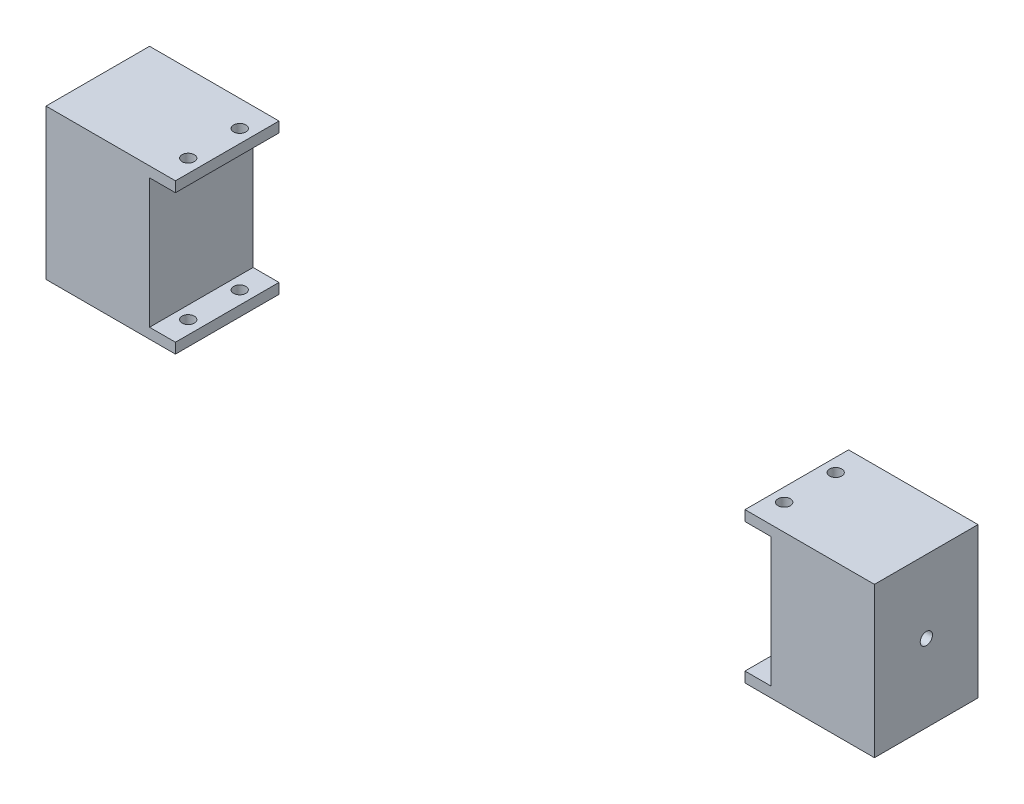
from build123d import *

# Parameters (mm, degrees)
SKETCH1_W                   = 25.4
SKETCH1_H                   = 25.4
MIAN_DEPTH                  = 31.75
SKETCH1_3_W                 = 6.35
SKETCH1_3_H                 = 25.4
SKETCH1_3_W_2               = 25.4
BOTTOM_LIP_DEPTH            = 2.54
TOP_START                   = 31.75
SKETCH1_4_W                 = 25.4
SKETCH1_4_H                 = 25.4
SKETCH1_4_W_2               = 6.35
TOP_LIP_DEPTH               = 2.54
HOLE_WIZARD_1474_AT_2_COUNT = 2
HOLE_WIZARD_1474_AT_2_PITCH = 12.636677574


with BuildPart() as part:
    # Sketch1 → mian (new body)
    with BuildSketch(Plane(origin=(0, 0, 0), x_dir=(1, 0, 0), z_dir=(0, 1, 0))):
        with Locations((-88.9, -12.7)):
            Rectangle(SKETCH1_W, SKETCH1_H)
    extrude(amount=MIAN_DEPTH)

    # Sketch1_3 → bottom lip (add)
    with BuildSketch(Plane(origin=(0, 0, 0), x_dir=(1, 0, 0), z_dir=(0, 1, 0))):
        with Locations((-73.025, -12.7)):
            Rectangle(SKETCH1_3_W, SKETCH1_3_H)
        with Locations((-88.9, -12.7)):
            Rectangle(SKETCH1_3_W_2, SKETCH1_3_H)
    extrude(amount=-BOTTOM_LIP_DEPTH)

    # Sketch1_4 → top lip (add)
    with BuildSketch(Plane(origin=(0, 0, 0), x_dir=(1, 0, 0), z_dir=(0, 1, 0)).offset(TOP_START)):
        with Locations((-88.9, -12.7)):
            Rectangle(SKETCH1_4_W, SKETCH1_4_H)
        with Locations((-73.025, -12.7)):
            Rectangle(SKETCH1_4_W_2, SKETCH1_4_H)
    extrude(amount=TOP_LIP_DEPTH)

    # Sketch10 → Hole Wizard 1474 (revolve, cut)
    with BuildSketch(Plane(origin=(-73.086678341, -2.54, 6.394154505), x_dir=(0, 0, -1), z_dir=(1, 0, 0))):
        Polygon((0, 0), (0, 8.521290929), (1.5, 7.62), (1.5, 0), align=None)
    hole_wizard_1474 = revolve(axis=Axis((-73.086678341, -8.89, 6.394154505), (0, 1, 0)), mode=Mode.SUBTRACT)

    # Hole Wizard 1474 at 2: Hole Wizard 1474 ×2
    with Locations(*[(0, 0, i * HOLE_WIZARD_1474_AT_2_PITCH) for i in range(1, HOLE_WIZARD_1474_AT_2_COUNT)]):
        add(hole_wizard_1474, mode=Mode.SUBTRACT)

    # Mirror4: Hole Wizard 1474 across plane
    add(hole_wizard_1474.mirror(Plane.ZX.offset(15.875)), mode=Mode.SUBTRACT)

    # Mirror4 copy 1 sketch → Mirror4 copy 1 (revolve, cut)
    with BuildSketch(Plane(origin=(-73.086678341, 34.29, 19.030832079), x_dir=(0, 0, -1), z_dir=(1, 0, 0))):
        Polygon((0, 0), (0, -8.521290929), (1.5, -7.62), (1.5, 0), align=None)
    revolve(axis=Axis((-73.086678341, 40.64, 19.030832079), (0, 1, 0)), mode=Mode.SUBTRACT)


with BuildPart() as body_2:
    # Mirror3: mirrored copy
    add(part.part.mirror(Plane(origin=(0, 0, 0), x_dir=(0, 0, 1), z_dir=(1, 0, 0))))

    # Sketch12 → Hole Wizard 3294 (revolve, cut)
    with BuildSketch(Plane(origin=(104.14, 16.427316548, 12.669354934), x_dir=(0, 0, -1), z_dir=(0, 1, 0))):
        Polygon((0, 0), (0, 8.521290929), (1.5, 7.62), (1.5, 0), align=None)
    revolve(axis=Axis((110.49, 16.427316548, 12.669354934), (-1, 0, 0)), mode=Mode.SUBTRACT)


with BuildPart() as part_1:
    add(part.part)

    # Sketch14 → Hole Wizard 3437 (revolve, cut)
    with BuildSketch(Plane(origin=(-104.14, 16.427316548, 12.669354934), x_dir=(0, 0, 1), z_dir=(0, 1, 0))):
        Polygon((0, 0), (0, 8.521290929), (1.5, 7.62), (1.5, 0), align=None)
    revolve(axis=Axis((-110.49, 16.427316548, 12.669354934), (1, 0, 0)), mode=Mode.SUBTRACT)


solid = Compound([body_2.part, part_1.part])
